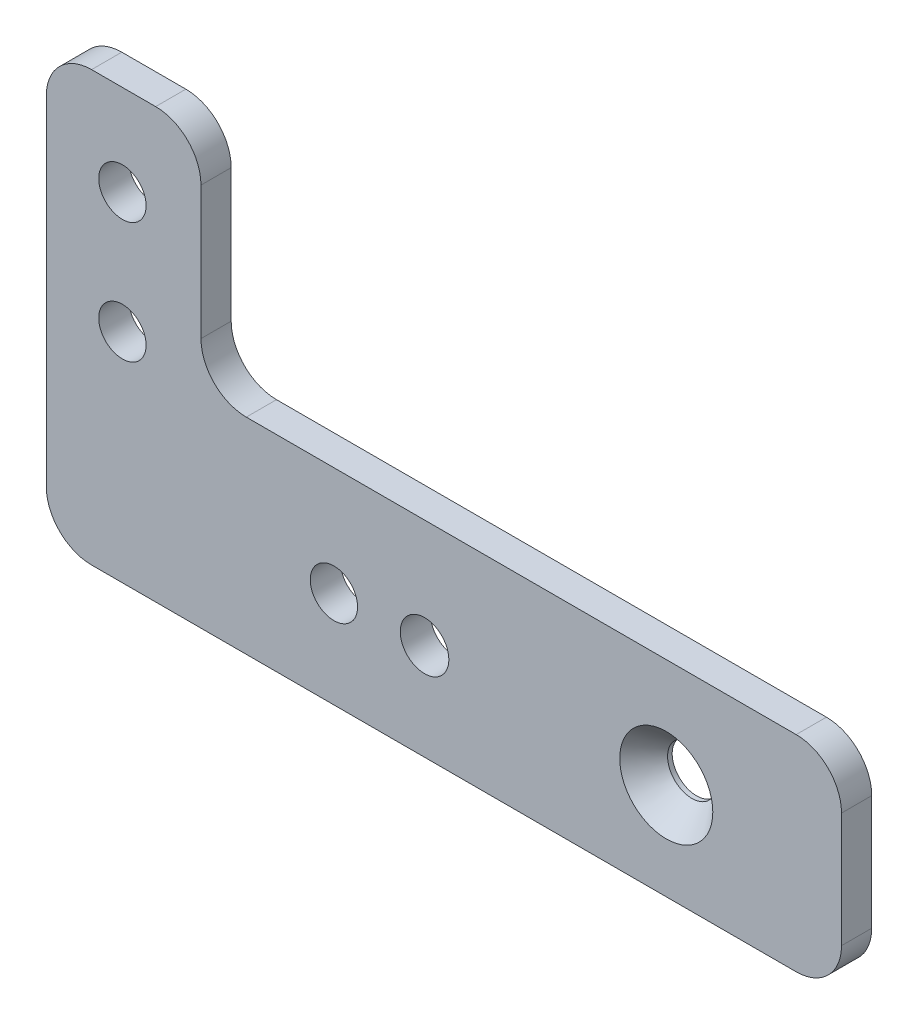
from build123d import *

# Parameters (mm, degrees)
SKETCH1_R                                       = 2.4892
SKETCH1_R_2                                     = 2.5527
BOSS_EXTRUDE1_DEPTH                             = 3.175
FILLET1_R                                       = 4.7625
CSK_FOR_10_FLAT_HEAD_MACHINE_SCREW1_D           = 5.1054
CSK_FOR_10_FLAT_HEAD_MACHINE_SCREW1_DEPTH       = 19.05
CSK_FOR_10_FLAT_HEAD_MACHINE_SCREW1_CSINK_D     = 9.779
CSK_FOR_10_FLAT_HEAD_MACHINE_SCREW1_CSINK_ANGLE = 82
CSK_FOR_10_FLAT_HEAD_MACHINE_SCREW1_TIP         = 1.533816902


with BuildPart() as part:
    # Sketch1 → Boss-Extrude1 (new body)
    with BuildSketch(Plane.XY):
        Polygon((-37.846, 23.8125), (-37.846, -21.2725), (45.72, -21.2725), (45.72, 0.3175), (-21.59, 0.3175), (-21.59, 23.8125), align=None)
        with Locations((-29.845, -11.1125)):
            Circle(SKETCH1_R, mode=Mode.SUBTRACT)
        with Locations((-7.62, -11.1125)):
            Circle(SKETCH1_R, mode=Mode.SUBTRACT)
        with Locations((1.905, -11.1125)):
            Circle(SKETCH1_R_2, mode=Mode.SUBTRACT)
        with Locations((27.305, -11.1125)):
            Circle(SKETCH1_R_2, mode=Mode.SUBTRACT)
        with Locations((-29.845, 1.5875)):
            Circle(SKETCH1_R, mode=Mode.SUBTRACT)
        with Locations((-29.845, 14.2875)):
            Circle(SKETCH1_R, mode=Mode.SUBTRACT)
        with Locations((-29.845, -11.1125)):
            Circle(SKETCH1_R)
    extrude(amount=BOSS_EXTRUDE1_DEPTH)

    # Fillet1
    fillet1_edges = [part.edges().sort_by_distance(p)[0] for p in [
        (-37.846, 23.8125, 1.5875),
        (-21.59, 23.8125, 1.5875),
        (-21.59, 0.3175, 1.5875),
        (45.72, 0.3175, 1.5875),
        (45.72, -21.2725, 1.5875),
        (-37.846, -21.2725, 1.5875),
    ]]
    fillet(fillet1_edges, radius=FILLET1_R)

    # CSK for #10 Flat Head Machine Screw1
    with Locations(Plane.XY.offset(3.175)):
        with Locations((27.305, -11.1125)):
            CounterSinkHole(CSK_FOR_10_FLAT_HEAD_MACHINE_SCREW1_D / 2, CSK_FOR_10_FLAT_HEAD_MACHINE_SCREW1_CSINK_D / 2, depth=CSK_FOR_10_FLAT_HEAD_MACHINE_SCREW1_DEPTH, counter_sink_angle=CSK_FOR_10_FLAT_HEAD_MACHINE_SCREW1_CSINK_ANGLE)
            with Locations((0, 0, -(CSK_FOR_10_FLAT_HEAD_MACHINE_SCREW1_DEPTH + CSK_FOR_10_FLAT_HEAD_MACHINE_SCREW1_TIP / 2))):  # 118° drill point
                Cone(0, CSK_FOR_10_FLAT_HEAD_MACHINE_SCREW1_D / 2, CSK_FOR_10_FLAT_HEAD_MACHINE_SCREW1_TIP, mode=Mode.SUBTRACT)


solid = part.part
